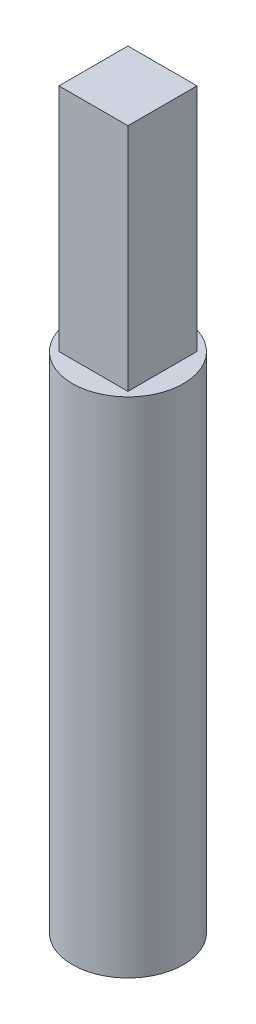
from build123d import *

# Parameters (mm, degrees)
SKETCH1_R           = 3.68046
BOSS_EXTRUDE1_DEPTH = 33.3375
SKETCH2_W           = 4.572
SKETCH2_H           = 4.572
BOSS_EXTRUDE2_DEPTH = 15.24


with BuildPart() as part:
    # Sketch1 → Boss-Extrude1 (new body)
    with BuildSketch(Plane(origin=(0, 0, 0), x_dir=(1, 0, 0), z_dir=(0, 1, 0))):
        Circle(SKETCH1_R)
    extrude(amount=BOSS_EXTRUDE1_DEPTH)

    # Sketch2 → Boss-Extrude2 (add)
    with BuildSketch(Plane(origin=(0, 33.3375, 0), x_dir=(1, 0, 0), z_dir=(0, 1, 0))):
        Rectangle(SKETCH2_W, SKETCH2_H)
    extrude(amount=BOSS_EXTRUDE2_DEPTH)


solid = part.part
